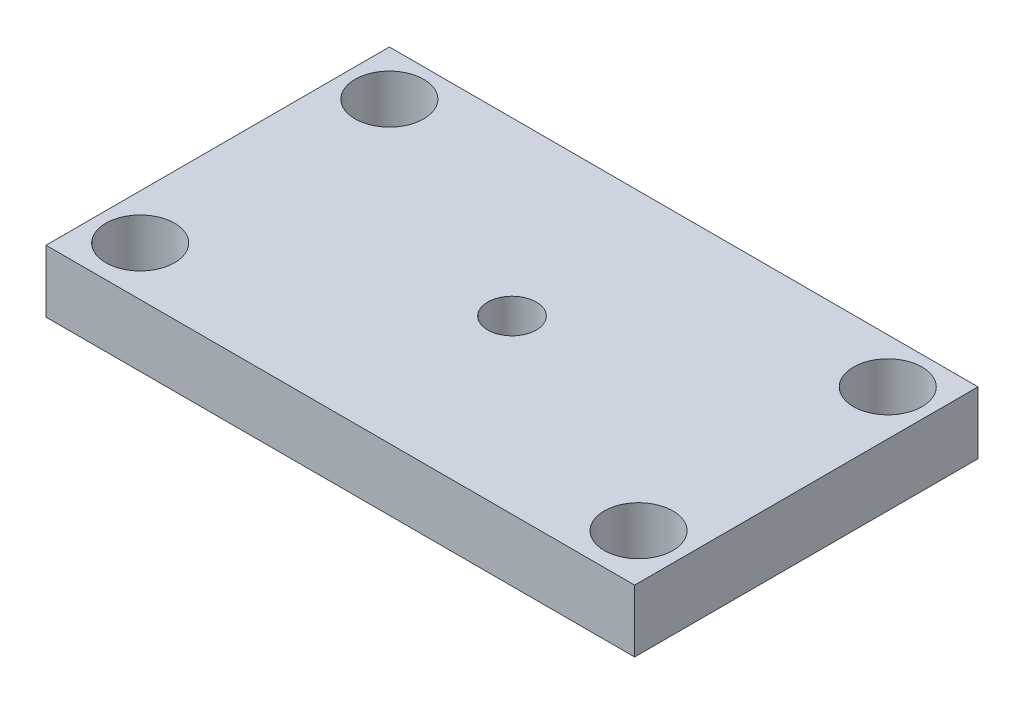
from build123d import *

# Parameters (mm, degrees)
SKETCH1_W           = 60
SKETCH1_H           = 35
SKETCH1_R           = 3.5
SKETCH1_R_2         = 2.475
BOSS_EXTRUDE1_DEPTH = 6.35


with BuildPart() as part:
    # Sketch1 → Boss-Extrude1 (new body)
    with BuildSketch(Plane(origin=(0, 0, 0), x_dir=(1, 0, 0), z_dir=(0, 1, 0))):
        with Locations((30, 17.5)):
            Rectangle(SKETCH1_W, SKETCH1_H)
        with Locations((4.6, 30.4)):
            Circle(SKETCH1_R, mode=Mode.SUBTRACT)
        with Locations((55.4, 30.4)):
            Circle(SKETCH1_R, mode=Mode.SUBTRACT)
        with Locations((4.6, 5)):
            Circle(SKETCH1_R, mode=Mode.SUBTRACT)
        with Locations((55.4, 5)):
            Circle(SKETCH1_R, mode=Mode.SUBTRACT)
        with Locations((30, 17.5)):
            Circle(SKETCH1_R_2, mode=Mode.SUBTRACT)
    extrude(amount=BOSS_EXTRUDE1_DEPTH)


solid = part.part
